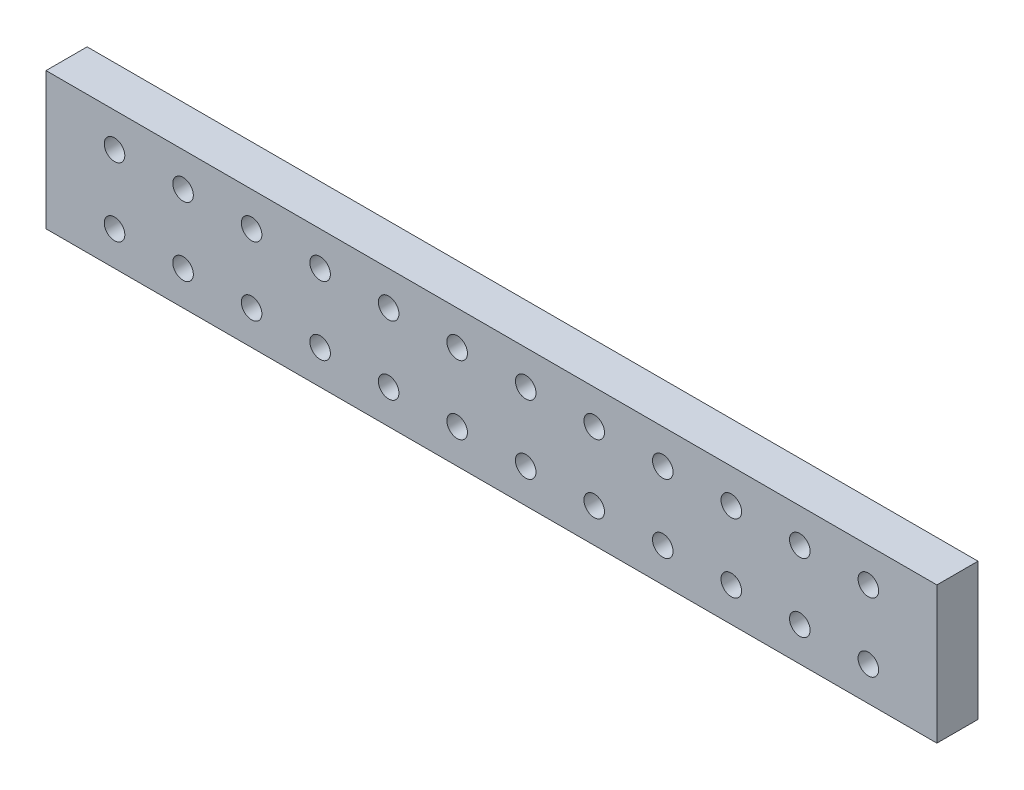
from build123d import *

# Parameters (mm, degrees)
SKETCH1_W           = 130
SKETCH1_H           = 20
SKETCH1_R           = 1.5
BOSS_EXTRUDE1_DEPTH = 6


with BuildPart() as part:
    # Sketch1 → Boss-Extrude1 (new body)
    with BuildSketch(Plane.XY):
        with Locations((4.266055046, 1.834862385)):
            Rectangle(SKETCH1_W, SKETCH1_H)
        with Locations((59.266055046, -3.165137615)):
            Circle(SKETCH1_R, mode=Mode.SUBTRACT)
        with Locations((59.266055046, 6.834862385)):
            Circle(SKETCH1_R, mode=Mode.SUBTRACT)
        with Locations((-50.733944954, -3.165137615)):
            Circle(SKETCH1_R, mode=Mode.SUBTRACT)
        with Locations((-50.733944954, 6.834862385)):
            Circle(SKETCH1_R, mode=Mode.SUBTRACT)
        with Locations((49.266055046, 6.834862385)):
            Circle(SKETCH1_R, mode=Mode.SUBTRACT)
        with Locations((39.266055046, 6.834862385)):
            Circle(SKETCH1_R, mode=Mode.SUBTRACT)
        with Locations((29.266055046, 6.834862385)):
            Circle(SKETCH1_R, mode=Mode.SUBTRACT)
        with Locations((19.266055046, 6.834862385)):
            Circle(SKETCH1_R, mode=Mode.SUBTRACT)
        with Locations((9.266055046, 6.834862385)):
            Circle(SKETCH1_R, mode=Mode.SUBTRACT)
        with Locations((49.266055046, -3.165137615)):
            Circle(SKETCH1_R, mode=Mode.SUBTRACT)
        with Locations((39.266055046, -3.165137615)):
            Circle(SKETCH1_R, mode=Mode.SUBTRACT)
        with Locations((29.266055046, -3.165137615)):
            Circle(SKETCH1_R, mode=Mode.SUBTRACT)
        with Locations((19.266055046, -3.165137615)):
            Circle(SKETCH1_R, mode=Mode.SUBTRACT)
        with Locations((9.266055046, -3.165137615)):
            Circle(SKETCH1_R, mode=Mode.SUBTRACT)
        with Locations((-40.733944954, -3.165137615)):
            Circle(SKETCH1_R, mode=Mode.SUBTRACT)
        with Locations((-40.733944954, 6.834862385)):
            Circle(SKETCH1_R, mode=Mode.SUBTRACT)
        with Locations((-30.733944954, 6.834862385)):
            Circle(SKETCH1_R, mode=Mode.SUBTRACT)
        with Locations((-30.733944954, -3.165137615)):
            Circle(SKETCH1_R, mode=Mode.SUBTRACT)
        with Locations((-20.733944954, -3.165137615)):
            Circle(SKETCH1_R, mode=Mode.SUBTRACT)
        with Locations((-20.733944954, 6.834862385)):
            Circle(SKETCH1_R, mode=Mode.SUBTRACT)
        with Locations((-10.733944954, 6.834862385)):
            Circle(SKETCH1_R, mode=Mode.SUBTRACT)
        with Locations((-10.733944954, -3.165137615)):
            Circle(SKETCH1_R, mode=Mode.SUBTRACT)
        with Locations((-0.733944954, -3.165137615)):
            Circle(SKETCH1_R, mode=Mode.SUBTRACT)
        with Locations((-0.733944954, 6.834862385)):
            Circle(SKETCH1_R, mode=Mode.SUBTRACT)
    extrude(amount=BOSS_EXTRUDE1_DEPTH)


solid = part.part
